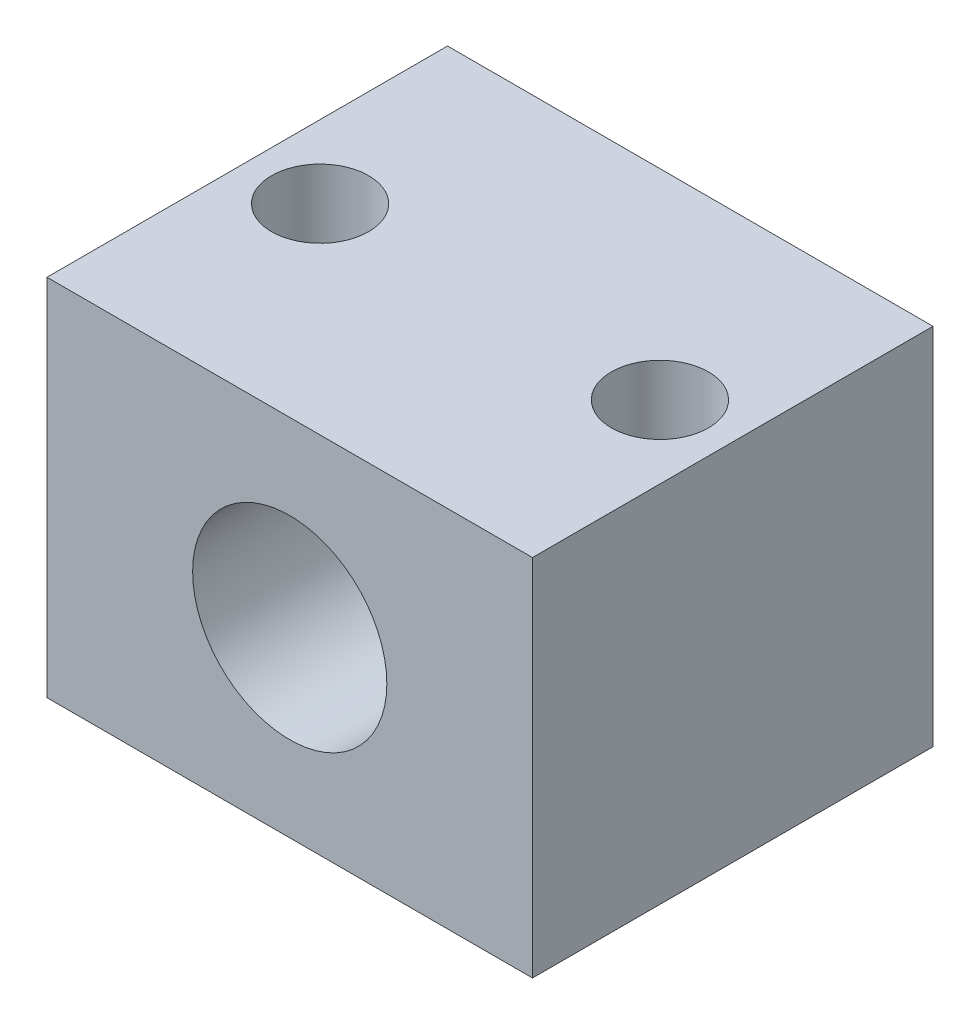
from build123d import *

# Parameters (mm, degrees)
ESQUISSE1_W      = 20
ESQUISSE1_H      = 15
ESQUISSE1_R      = 4
EXTRUSION1_DEPTH = 16.5
ESQUISSE2_R      = 2
EXTRUSION3_DEPTH = 16


with BuildPart() as part:
    # Esquisse1 → Extrusion1 (new body)
    with BuildSketch(Plane.XY):
        with Locations((-10, -7.5)):
            Rectangle(ESQUISSE1_W, ESQUISSE1_H)
        with Locations((-10, -7.5)):
            Circle(ESQUISSE1_R, mode=Mode.SUBTRACT)
    extrude(amount=EXTRUSION1_DEPTH)

    # Esquisse2 → Extrusion3 (cut, through all)
    with BuildSketch(Plane(origin=(0, 0, 0), x_dir=(1, 0, 0), z_dir=(0, 1, 0))):
        with Locations((-17, -8.25)):
            Circle(ESQUISSE2_R)
        with Locations((-3, -8.25)):
            Circle(ESQUISSE2_R)
    extrude(amount=-EXTRUSION3_DEPTH, mode=Mode.SUBTRACT)


solid = part.part
